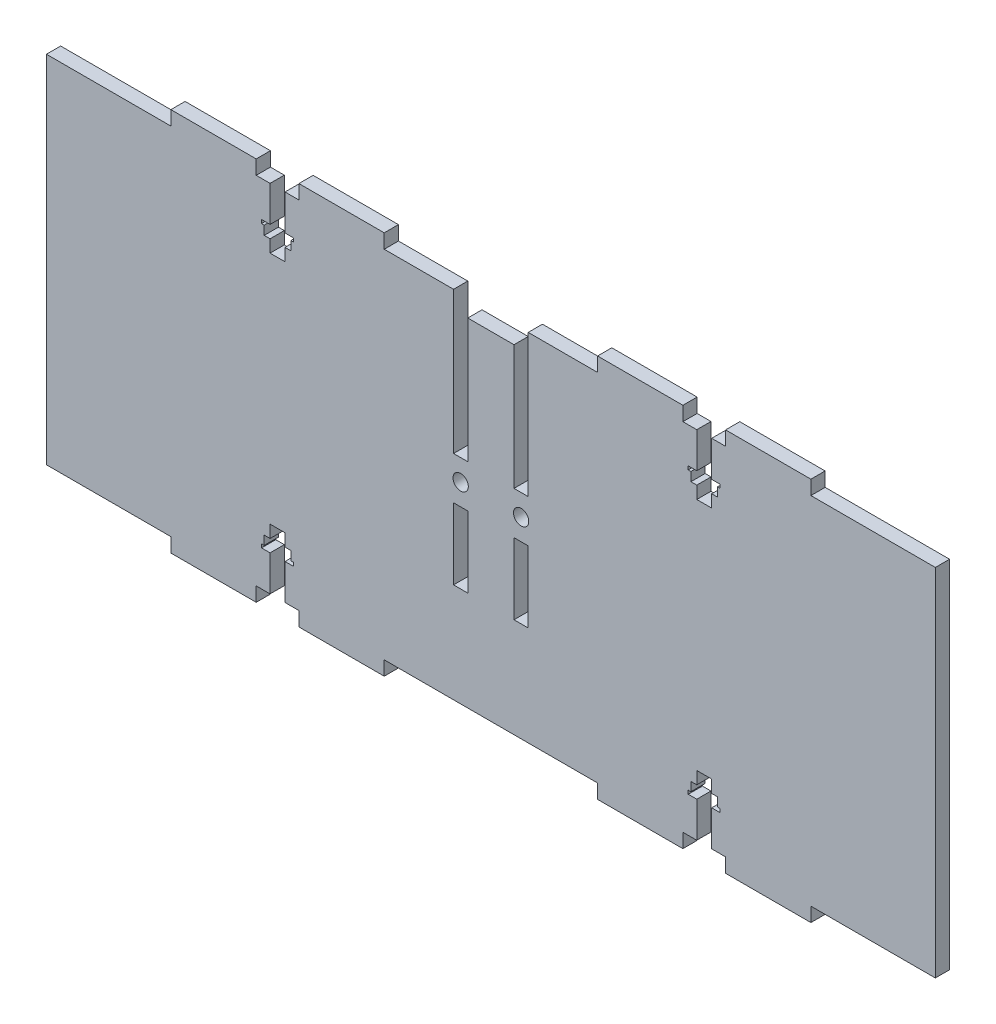
from build123d import *

# Parameters (mm, degrees)
SKETCH1_W                = 250
SKETCH1_H                = 100
BOSS_EXTRUDE1_DEPTH      = 4
SKETCH2_W                = 24
SKETCH2_H                = 4
BOSS_EXTRUDE2_DEPTH      = 4
SKETCH3_W                = 4
SKETCH3_H                = 40
SKETCH3_H_2              = 20
CUT_EXTRUDE1_DEPTH       = 5
M4_CLEARANCE_HOLE1_D     = 4.3
M4_CLEARANCE_HOLE1_DEPTH = 6
M4_CLEARANCE_HOLE1_TIP   = 1.291850331
CUT_EXTRUDE2_DEPTH       = 10
SKETCH7_W                = 13
SKETCH7_H                = 5
CUT_EXTRUDE3_DEPTH       = 10


with BuildPart() as part:
    # Sketch1 → Boss-Extrude1 (new body)
    with BuildSketch(Plane.XY):
        Rectangle(SKETCH1_W, SKETCH1_H)
    extrude(amount=BOSS_EXTRUDE1_DEPTH)

    # Sketch2 → Boss-Extrude2 (add)
    with BuildSketch(Plane.XZ.offset(50)):
        with Locations((-78, 2)):
            Rectangle(SKETCH2_W, SKETCH2_H)
        with Locations((-42, 2)):
            Rectangle(SKETCH2_W, SKETCH2_H)
        with Locations((42, 2)):
            Rectangle(SKETCH2_W, SKETCH2_H)
        with Locations((78, 2)):
            Rectangle(SKETCH2_W, SKETCH2_H)
    boss_extrude2 = extrude(amount=BOSS_EXTRUDE2_DEPTH)

    # Sketch3 → Cut-Extrude1 (cut, through all)
    with BuildSketch(Plane.XY.offset(4)):
        with Locations((-8.5, 30)):
            Rectangle(SKETCH3_W, SKETCH3_H)
        with Locations((-8.5, -12)):
            Rectangle(SKETCH3_W, SKETCH3_H_2)
        with Locations((8.5, -12)):
            Rectangle(SKETCH3_W, SKETCH3_H_2)
        with Locations((8.5, 30)):
            Rectangle(SKETCH3_W, SKETCH3_H)
    extrude(amount=-CUT_EXTRUDE1_DEPTH, mode=Mode.SUBTRACT)

    # Mirror1: Boss-Extrude2 across plane
    add(boss_extrude2.mirror(Plane.ZX))

    # M4 Clearance Hole1
    with Locations(Plane.XY.offset(4)):
        with Locations((-8.5, 4), (8.5, 4)):
            Hole(M4_CLEARANCE_HOLE1_D / 2, depth=M4_CLEARANCE_HOLE1_DEPTH)
            with Locations((0, 0, -(M4_CLEARANCE_HOLE1_DEPTH + M4_CLEARANCE_HOLE1_TIP / 2))):  # 118° drill point
                Cone(0, M4_CLEARANCE_HOLE1_D / 2, M4_CLEARANCE_HOLE1_TIP, mode=Mode.SUBTRACT)

    # Sketch6 → Cut-Extrude2 (cut)
    with BuildSketch(Plane.XY.offset(4)):
        Polygon((-62.1, -50), (-57.9, -50), (-57.9, -40), (-55.5, -40), (-55.5, -39), (-56.25, -39), (-56.25, -36.5), (-57.9, -36.5), (-57.9, -33), (-62.1, -33), (-62.1, -36.5), (-63.75, -36.5), (-63.75, -39), (-64.5, -39), (-64.5, -40), (-62.1, -40), align=None)
        Polygon((57.9, -40), (57.9, -50), (62.1, -50), (62.1, -40), (64.5, -40), (64.5, -39), (63.75, -39), (63.75, -36.5), (62.1, -36.5), (62.1, -33), (57.9, -33), (57.9, -36.5), (56.25, -36.5), (56.25, -39), (55.5, -39), (55.5, -40), align=None)
        Polygon((62.1, 40), (62.1, 50), (57.9, 50), (57.9, 40), (55.5, 40), (55.5, 39), (56.25, 39), (56.25, 36.5), (57.9, 36.5), (57.9, 33), (62.1, 33), (62.1, 36.5), (63.75, 36.5), (63.75, 39), (64.5, 39), (64.5, 40), align=None)
        Polygon((-57.9, 50), (-62.1, 50), (-62.1, 40), (-64.5, 40), (-64.5, 39), (-63.75, 39), (-63.75, 36.5), (-62.1, 36.5), (-62.1, 33), (-57.9, 33), (-57.9, 36.5), (-56.25, 36.5), (-56.25, 39), (-55.5, 39), (-55.5, 40), (-57.9, 40), align=None)
    extrude(amount=-CUT_EXTRUDE2_DEPTH, mode=Mode.SUBTRACT)

    # Sketch7 → Cut-Extrude3 (cut)
    with BuildSketch(Plane.XY.offset(4)):
        with Locations((0, 47.5)):
            Rectangle(SKETCH7_W, SKETCH7_H)
    extrude(amount=-CUT_EXTRUDE3_DEPTH, mode=Mode.SUBTRACT)


solid = part.part
